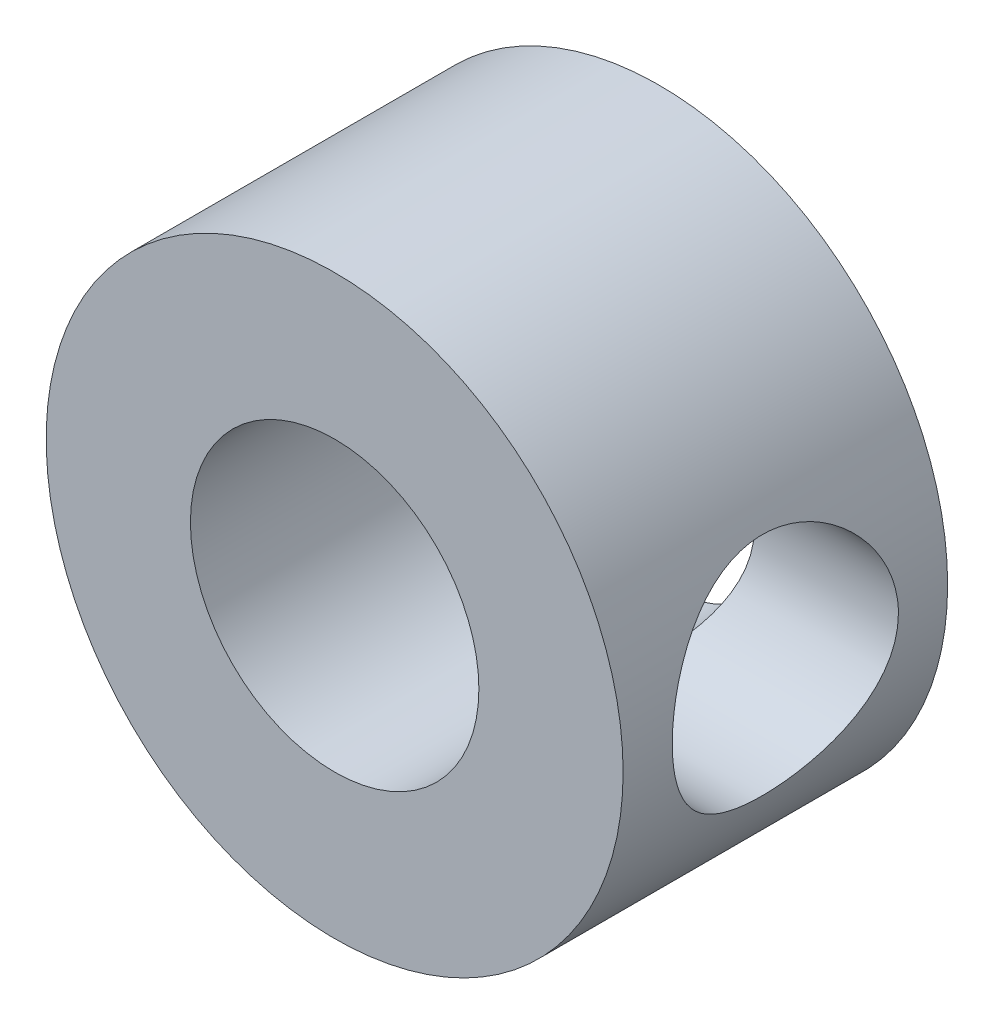
from build123d import *

# Parameters (mm, degrees)
SKETCH1_R                       = 6.35
SKETCH1_R_2                     = 3.175
EXTRUDE1_DEPTH                  = 7.14375
F_9_0_196_DIAMETER_HOLE2_REACH  = 17.895
F_9_0_196_DIAMETER_HOLE2_BORE_R = 2.4892


with BuildPart() as part:
    # Sketch1 → Extrude1 (new body)
    with BuildSketch(Plane.XY):
        Circle(SKETCH1_R)
        Circle(SKETCH1_R_2, mode=Mode.SUBTRACT)
    extrude(amount=EXTRUDE1_DEPTH)

    # #9 (0.196) Diameter Hole2 bore → #9 (0.196) Diameter Hole2 (cut, up to next)
    with BuildSketch(Plane(origin=(6.35, 0, 0), x_dir=(0, 0, -1), z_dir=(1, 0, 0)), mode=Mode.PRIVATE) as f_9_0_196_diameter_hole2_sk1:
        with Locations((-3.572568118, 0)):
            Circle(F_9_0_196_DIAMETER_HOLE2_BORE_R)
    f_9_0_196_diameter_hole2_tool1 = extrude(f_9_0_196_diameter_hole2_sk1.sketch, amount=-F_9_0_196_DIAMETER_HOLE2_REACH, mode=Mode.PRIVATE) & part.part
    add(f_9_0_196_diameter_hole2_tool1.solids().sort_by_distance((6.35, 0, 3.572568))[0], mode=Mode.SUBTRACT)


solid = part.part
